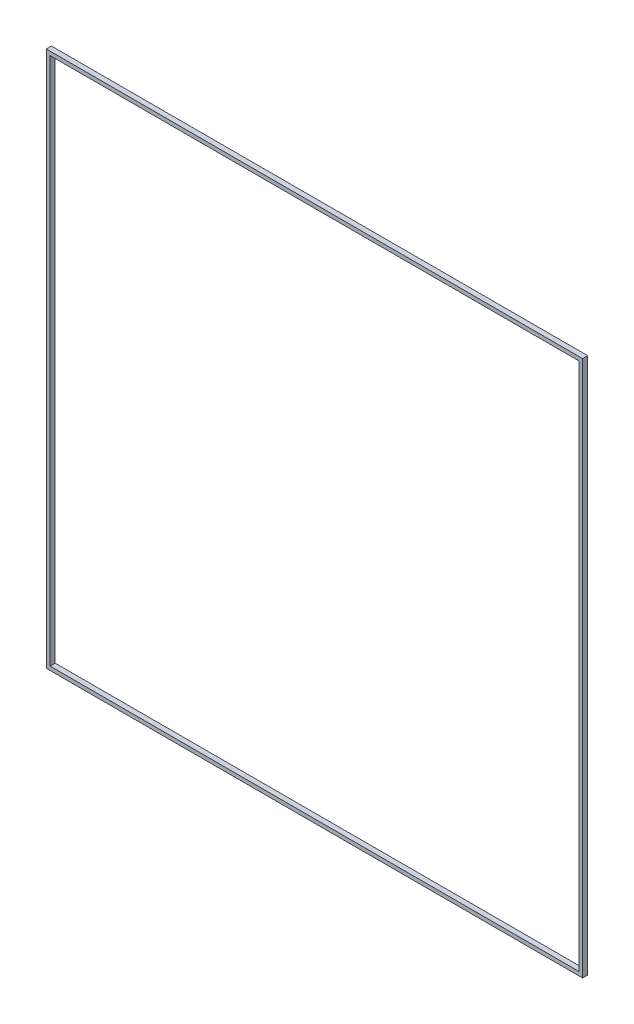
from build123d import *

# Parameters (mm, degrees)
SKETCH1_W           = 210
SKETCH1_H           = 210
BOSS_EXTRUDE1_DEPTH = 2
SKETCH2_W           = 207
SKETCH2_H           = 207
CUT_EXTRUDE2_DEPTH  = 3


with BuildPart() as part:
    # Sketch1 → Boss-Extrude1 (new body)
    with BuildSketch(Plane.XY):
        Rectangle(SKETCH1_W, SKETCH1_H)
    extrude(amount=BOSS_EXTRUDE1_DEPTH)

    # Sketch2 → Cut-Extrude2 (cut, through all)
    with BuildSketch(Plane.XY.offset(2)):
        Rectangle(SKETCH2_W, SKETCH2_H)
    extrude(amount=-CUT_EXTRUDE2_DEPTH, mode=Mode.SUBTRACT)


solid = part.part
